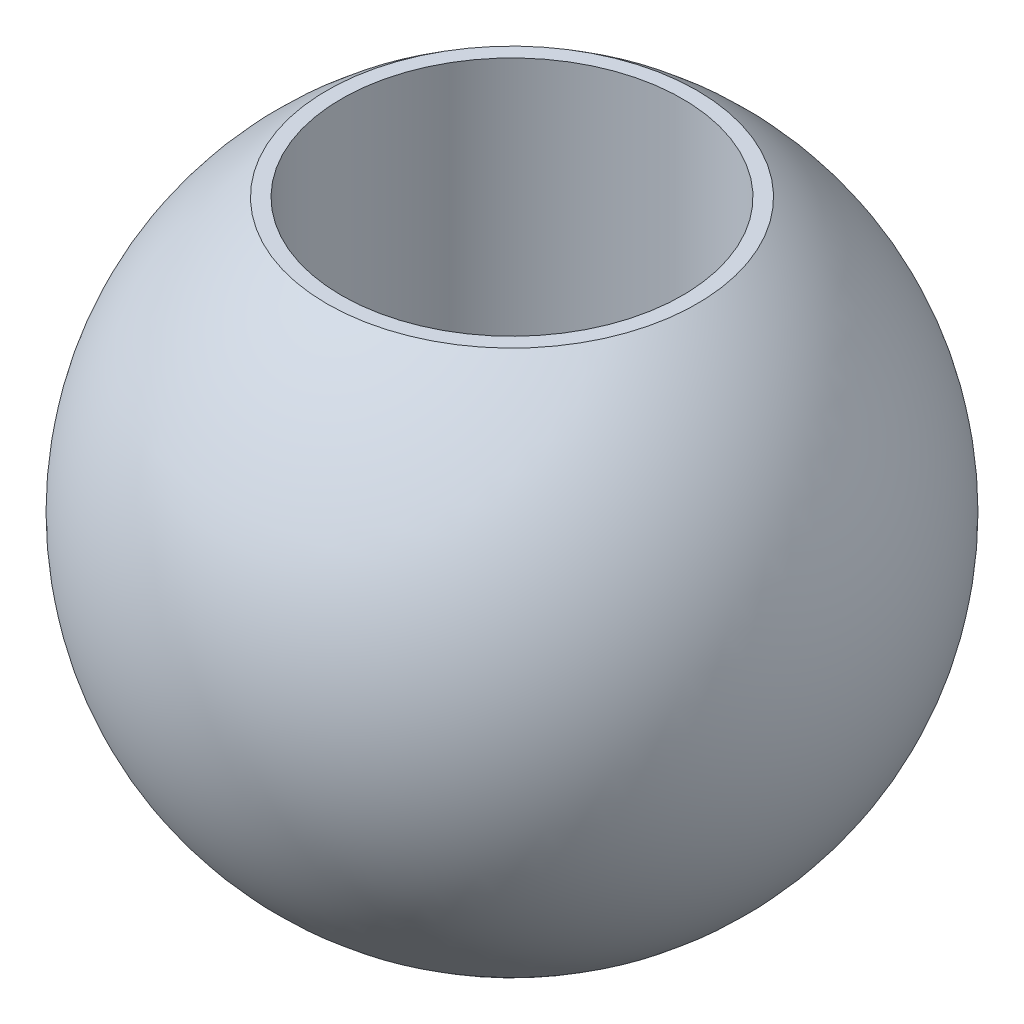
from build123d import *
from build123d.topology import SkipClean

# Parameters (mm, degrees)
CUT_EXTRUDE_1_DEPTH = 5
SKETCH_3_R          = 1.5
CUT_EXTRUDE_2_DEPTH = 9.067837381


with BuildPart() as part:
    # 草图1 → 旋转1 (revolve)
    with BuildSketch(Plane.XY):
        with BuildLine():
            Line((0, 0), (5.8, 0))
            ThreePointArc((5.8, 0), (2.9, 2.9), (0, 0))
        make_face()
    revolve(axis=Axis((0, 0, 0), (1, 0, 0)))

    # 草图2 → 切除-拉伸1 (cut, symmetric)
    with SkipClean():  # the faces are left unmerged after this step: merging them gives an invalid solid
        with BuildSketch(Plane.XY):
            with BuildLine():
                Line((1.27211794, -2.4), (4.52788206, -2.4))
                ThreePointArc((4.52788206, -2.4), (2.9, -2.9), (1.27211794, -2.4))
            make_face()
            with BuildLine():
                Line((1.27211794, 2.4), (4.52788206, 2.4))
                ThreePointArc((4.52788206, 2.4), (2.9, 2.9), (1.27211794, 2.4))
            make_face()
        extrude(amount=CUT_EXTRUDE_1_DEPTH, both=True, mode=Mode.SUBTRACT)

    # 草图3 → 切除-拉伸2 (cut, through all)
    with SkipClean():  # the faces are left unmerged after this step: merging them gives an invalid solid
        with BuildSketch(Plane(origin=(0, 2.4, 0), x_dir=(1, 0, 0), z_dir=(0, 1, 0))):
            with Locations(Location((2.9, 0, 0), (0, 0, 270))):
                Circle(SKETCH_3_R)
        extrude(amount=-CUT_EXTRUDE_2_DEPTH, mode=Mode.SUBTRACT)


solid = part.part
